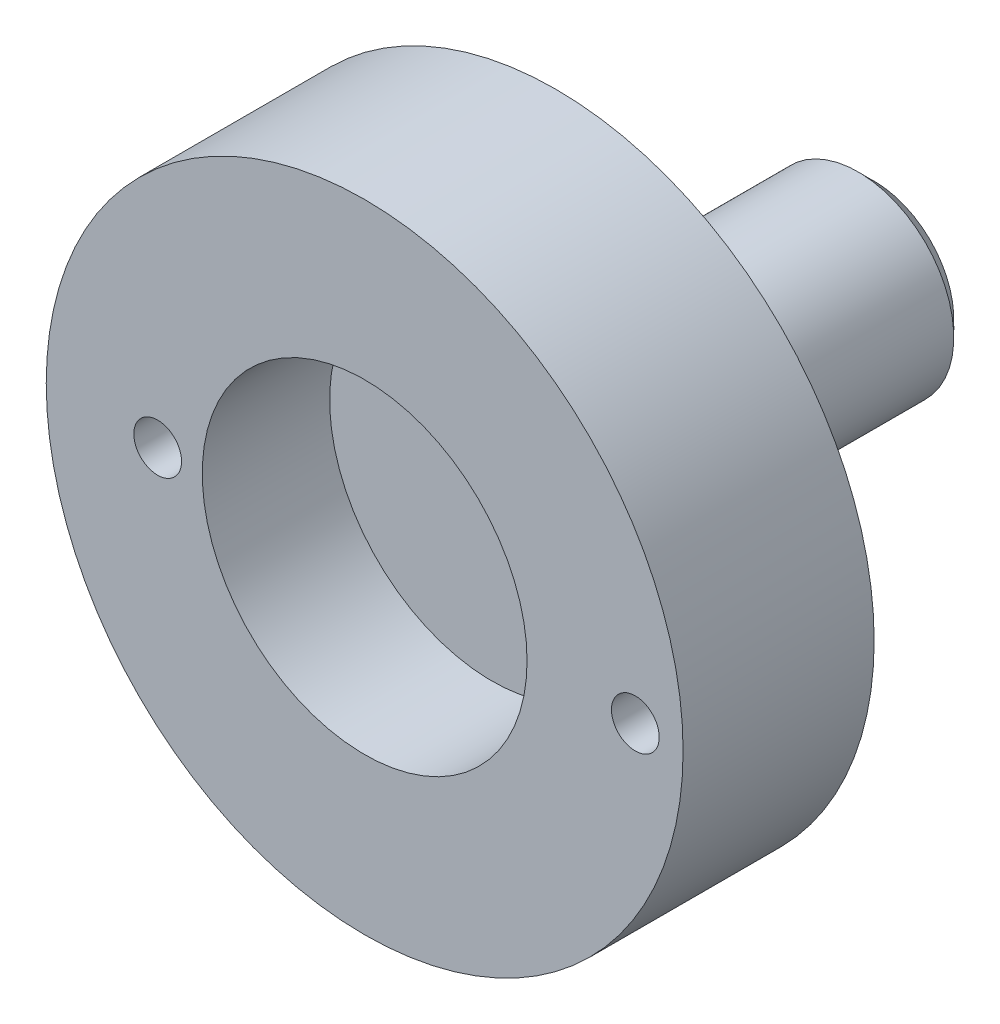
from build123d import *

# Parameters (mm, degrees)
SKETCH1_R           = 10
SKETCH1_R_2         = 5.1
BOSS_EXTRUDE1_DEPTH = 4
SKETCH3_R           = 3
BOSS_EXTRUDE2_DEPTH = 12
SKETCH4_R           = 10
SKETCH4_R_2         = 3
BOSS_EXTRUDE3_DEPTH = 2
CHAMFER2_SIZE       = 1
CHAMFER4_SIZE       = 0.5
CUT_EXTRUDE1_REACH  = 8
SKETCH5_R           = 0.75


with BuildPart() as part:
    # Sketch1 → Boss-Extrude1 (new body)
    with BuildSketch(Plane.XY):
        Circle(SKETCH1_R)
        Circle(SKETCH1_R_2, mode=Mode.SUBTRACT)
    extrude(amount=BOSS_EXTRUDE1_DEPTH)



with BuildPart() as body_2:
    # Sketch3 → Boss-Extrude2 (new body)
    with BuildSketch(Plane(origin=(0, 0, 0), x_dir=(-1, 0, 0), z_dir=(0, 0, -1))):
        Circle(SKETCH3_R)
    extrude(amount=BOSS_EXTRUDE2_DEPTH)


with BuildPart() as part_1:
    add(part.part)

    add(body_2.part)  # Boss-Extrude3 merges body 2
    # Sketch4 → Boss-Extrude3 (add)
    with BuildSketch(Plane(origin=(0, 0, 0), x_dir=(-1, 0, 0), z_dir=(0, 0, -1))):
        Circle(SKETCH4_R)
        Circle(SKETCH4_R_2, mode=Mode.SUBTRACT)
    extrude(amount=BOSS_EXTRUDE3_DEPTH)

    # Chamfer2
    chamfer2_edges = [part_1.edges().sort_by_distance(p)[0] for p in [
        (3, 0, -2),
    ]]
    chamfer(chamfer2_edges, length=CHAMFER2_SIZE)

    # Chamfer4
    chamfer4_edges = [part_1.edges().sort_by_distance(p)[0] for p in [
        (3, 0, -12),
    ]]
    chamfer(chamfer4_edges, length=CHAMFER4_SIZE)

    # Sketch5 → Cut-Extrude1 (cut, up to next)
    with BuildSketch(Plane(origin=(0, 0, -2), x_dir=(-1, 0, 0), z_dir=(0, 0, -1)), mode=Mode.PRIVATE) as cut_extrude1_sk1:
        with Locations((-8.5, 0)):
            Circle(SKETCH5_R)
    cut_extrude1_tool1 = extrude(cut_extrude1_sk1.sketch, amount=-CUT_EXTRUDE1_REACH, mode=Mode.PRIVATE) & part_1.part
    add(cut_extrude1_tool1.solids().sort_by_distance((8.5, 0, -2))[0], mode=Mode.SUBTRACT)
    # Sketch5 → Cut-Extrude1 (cut, up to next)
    with BuildSketch(Plane(origin=(0, 0, -2), x_dir=(-1, 0, 0), z_dir=(0, 0, -1)), mode=Mode.PRIVATE) as cut_extrude1_sk2:
        with Locations((6.5, 0)):
            Circle(SKETCH5_R)
    cut_extrude1_tool2 = extrude(cut_extrude1_sk2.sketch, amount=-CUT_EXTRUDE1_REACH, mode=Mode.PRIVATE) & part_1.part
    add(cut_extrude1_tool2.solids().sort_by_distance((-6.5, 0, -2))[0], mode=Mode.SUBTRACT)


solid = part_1.part
